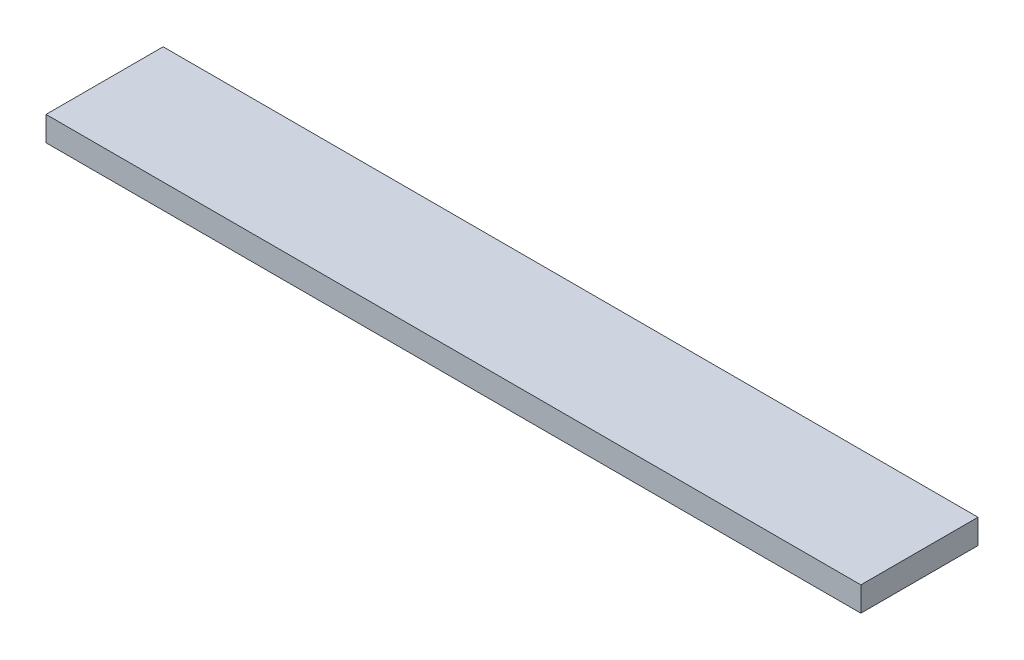
from build123d import *

# Parameters (mm, degrees)
SKETCH1_W           = 631.7488
SKETCH1_H           = 90.8304
BOSS_EXTRUDE1_DEPTH = 19.05


with BuildPart() as part:
    # Sketch1 → Boss-Extrude1 (new body)
    with BuildSketch(Plane(origin=(0, 0, 0), x_dir=(1, 0, 0), z_dir=(0, 1, 0))):
        with Locations((315.8744, 45.4152)):
            Rectangle(SKETCH1_W, SKETCH1_H)
    extrude(amount=BOSS_EXTRUDE1_DEPTH)


solid = part.part
